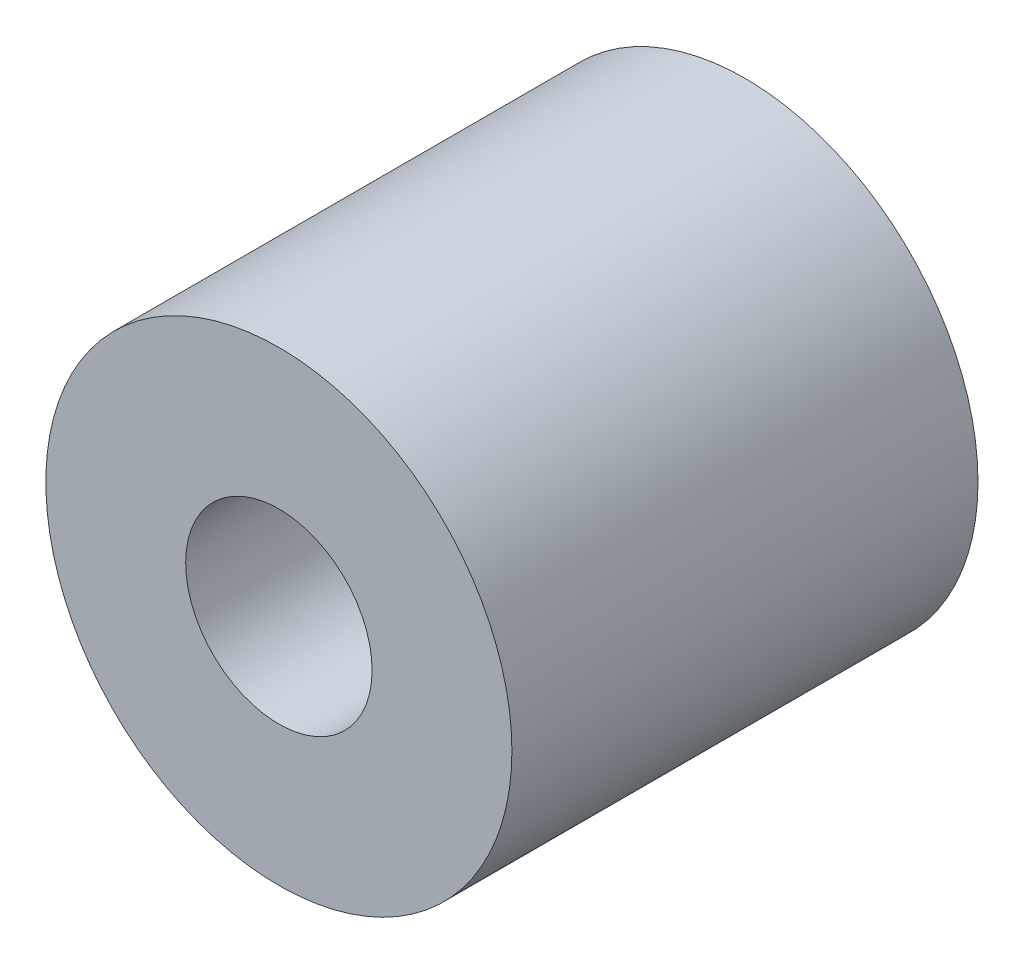
from build123d import *

# Parameters (mm, degrees)
ESBO_O1_R                = 12.5
ESBO_O1_R_2              = 5
RESSALTO_EXTRUS_O1_DEPTH = 25


with BuildPart() as part:
    # Esboço1 → Ressalto-extrusão1 (new body)
    with BuildSketch(Plane.XY):
        Circle(ESBO_O1_R)
        Circle(ESBO_O1_R_2, mode=Mode.SUBTRACT)
    extrude(amount=RESSALTO_EXTRUS_O1_DEPTH)


solid = part.part
